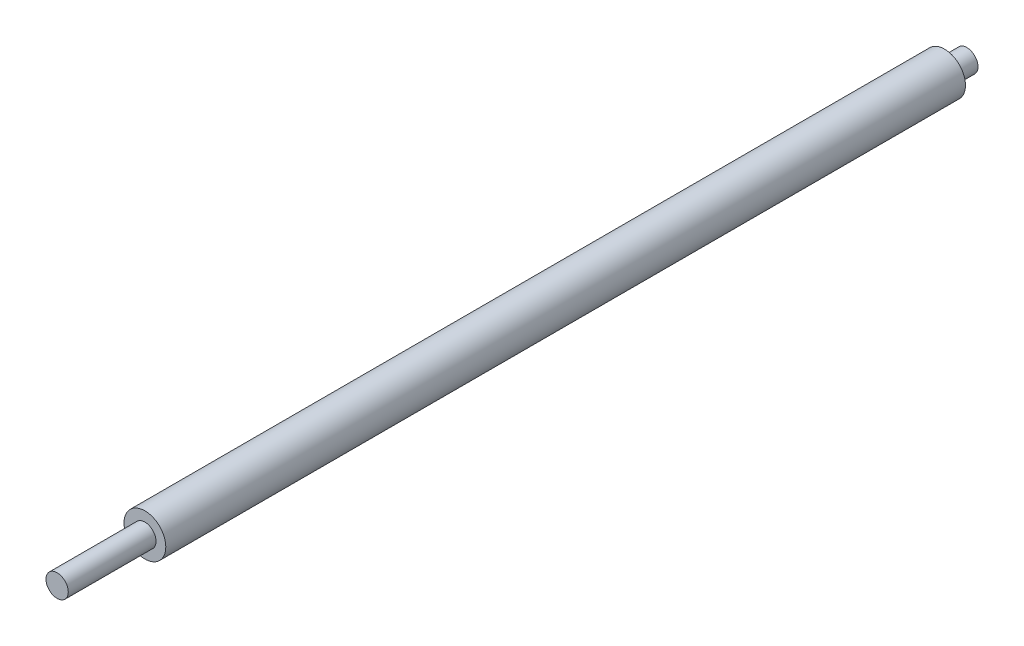
from build123d import *

# Parameters (mm, degrees)
SKETCH_1_R      = 4
EXTRUDE_1_DEPTH = 8
SKETCH_2_R      = 7.5
EXTRUDE_2_DEPTH = 287
SKETCH_3_R      = 4
EXTRUDE_3_DEPTH = 31.5


with BuildPart() as part:
    # 草图1 → 凸台-拉伸1 (new body)
    with BuildSketch(Plane.XY):
        Circle(SKETCH_1_R)
    extrude(amount=EXTRUDE_1_DEPTH)

    # 草图2 → 凸台-拉伸2 (add)
    with BuildSketch(Plane.XY.offset(8)):
        Circle(SKETCH_2_R)
    extrude(amount=EXTRUDE_2_DEPTH)

    # 草图3 → 凸台-拉伸3 (add)
    with BuildSketch(Plane.XY.offset(295)):
        Circle(SKETCH_3_R)
    extrude(amount=EXTRUDE_3_DEPTH)


solid = part.part
